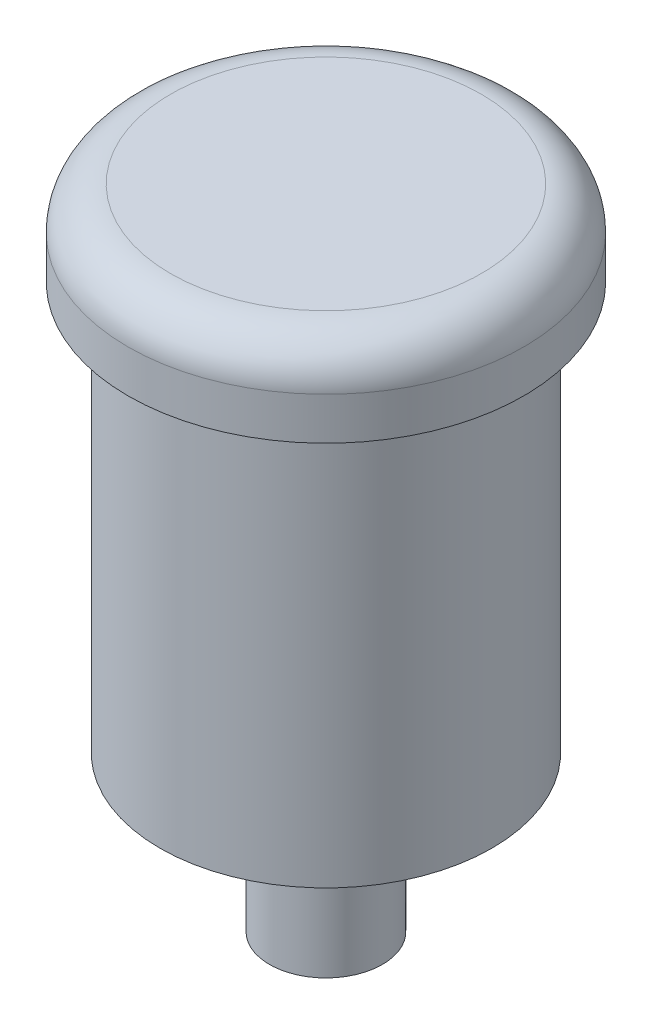
from build123d import *

# Parameters (mm, degrees)
SKETCH1_R           = 14
BOSS_EXTRUDE1_DEPTH = 6
SKETCH2_R           = 11.75
BOSS_EXTRUDE2_DEPTH = 28.85
FILLET1_R           = 3
SKETCH3_R           = 4
BOSS_EXTRUDE3_DEPTH = 11


with BuildPart() as part:
    # Sketch1 → Boss-Extrude1 (new body)
    with BuildSketch(Plane(origin=(0, 0, 0), x_dir=(1, 0, 0), z_dir=(0, 1, 0))):
        with Locations((-10.425597089, 8.327180584)):
            Circle(SKETCH1_R)
    extrude(amount=BOSS_EXTRUDE1_DEPTH)

    # Sketch2 → Boss-Extrude2 (add)
    with BuildSketch(Plane.XZ):
        with Locations((-10.425597089, -8.327180584)):
            Circle(SKETCH2_R)
    extrude(amount=BOSS_EXTRUDE2_DEPTH)

    # Fillet1
    fillet1_edges = [part.edges().sort_by_distance(p)[0] for p in [
        (-24.425597089, 6, -8.327180584),
    ]]
    fillet(fillet1_edges, radius=FILLET1_R)

    # Sketch3 → Boss-Extrude3 (add)
    with BuildSketch(Plane.XZ.offset(28.85)):
        with Locations((-10.425597089, -8.327180584)):
            Circle(SKETCH3_R)
    extrude(amount=BOSS_EXTRUDE3_DEPTH)


solid = part.part
